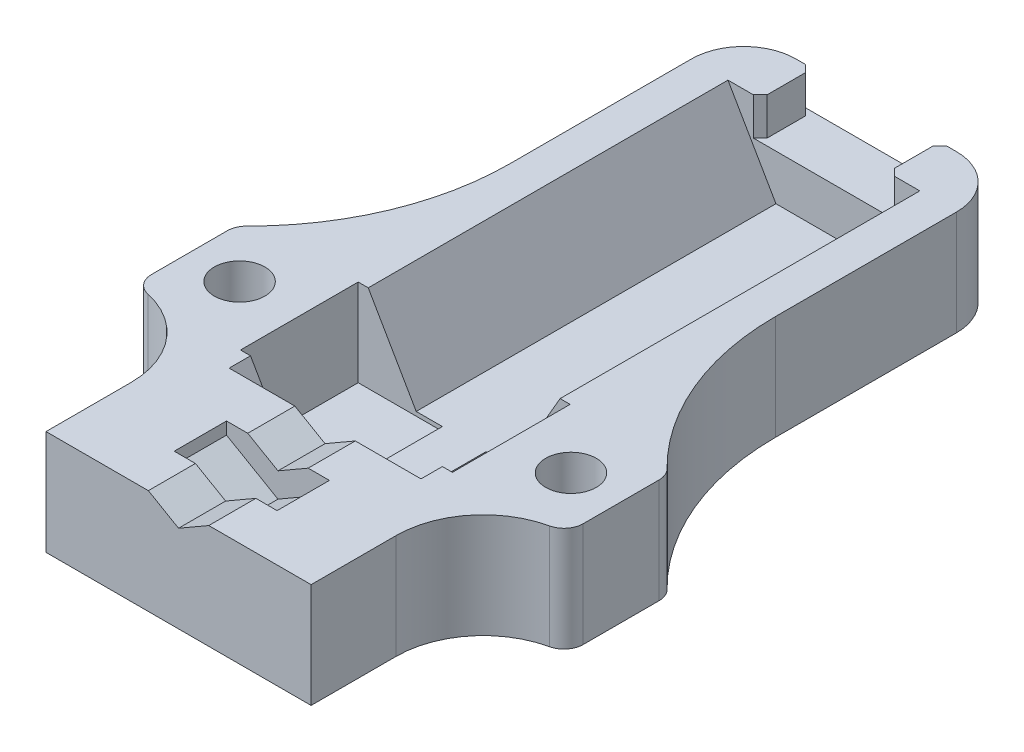
from build123d import *

# Parameters (mm, degrees)
ESBO_O2_R                = 1.6
RESSALTO_EXTRUS_O1_DEPTH = 6
ESBO_O3_W                = 4.825
ESBO_O3_H                = 6.75
CORTE_EXTRUS_O1_DEPTH    = 5
CORTE_EXTRUS_O10_DEPTH   = 28.6
ESBO_O18_W               = 7.3
ESBO_O18_H               = 2.15
CORTE_EXTRUS_O13_DEPTH   = 3
ESBO_O19_R               = 1.6
RESSALTO_EXTRUS_O2_DEPTH = 1
ESBO_O25_R               = 1.6
ESBO_O25_R_2             = 1.45
RESSALTO_EXTRUS_O3_DEPTH = 5
CHANFRO1_SIZE            = 0.4
CORTE_EXTRUS_O16_DEPTH   = 0.3
CORTE_EXTRUS_O17_DEPTH   = 0.3
CORTE_EXTRUS_O18_DEPTH   = 1.5
CORTE_EXTRUS_O19_DEPTH   = 8.4


with BuildPart() as part:
    # Esboço2 → Ressalto-extrusão1 (new body)
    with BuildSketch(Plane.XZ.offset(4.549476945)):
        with BuildLine():
            Line((8.345502404, 42.825), (8.345502404, 47.175))
            ThreePointArc((8.345502404, 47.175), (8.103648042, 47.863175897), (7.484436831, 48.248736625))
            ThreePointArc((7.484436831, 48.248736625), (4.669840418, 50.001285388), (3.570502404, 53.129357648))
            Line((3.570502404, 53.129357648), (3.570502404, 58))
            Line((3.570502404, 58), (-11.629497596, 58))
            Line((-11.629497596, 58), (-11.629497596, 53.129357648))
            ThreePointArc((-11.629497596, 53.129357648), (-12.728835609, 50.001285388), (-15.543432022, 48.248736625))
            ThreePointArc((-15.543432022, 48.248736625), (-16.162643233, 47.863175897), (-16.404497596, 47.175))
            Line((-16.404497596, 47.175), (-16.404497596, 42.825))
            ThreePointArc((-16.404497596, 42.825), (-16.319665941, 42.401404403), (-16.07825536, 42.043143925))
            ThreePointArc((-16.07825536, 42.043143925), (-12.786292881, 37.157773764), (-11.629497596, 31.381470169))
            Line((-11.629497596, 31.381470169), (-11.629497596, 21))
            ThreePointArc((-11.629497596, 21), (-10.750817939, 18.878679656), (-8.629497596, 18))
            Line((-8.629497596, 18), (0.570502404, 18))
            ThreePointArc((0.570502404, 18), (2.691822748, 18.878679656), (3.570502404, 21))
            Line((3.570502404, 21), (3.570502404, 31.381470169))
            ThreePointArc((3.570502404, 31.381470169), (4.72729769, 37.157773764), (8.019260168, 42.043143925))
            ThreePointArc((8.019260168, 42.043143925), (8.26067075, 42.401404403), (8.345502404, 42.825))
        make_face()
        with Locations((5.470502404, 45)):
            Circle(ESBO_O2_R, mode=Mode.SUBTRACT)
        with Locations((-13.529497596, 45)):
            Circle(ESBO_O2_R, mode=Mode.SUBTRACT)
    extrude(amount=RESSALTO_EXTRUS_O1_DEPTH)

    # Esboço3 → Corte-extrusão1 (cut)
    with BuildSketch(Plane.XZ.offset(4.549476945)):
        with Locations((-7.691997596, 45)):
            Rectangle(ESBO_O3_W, ESBO_O3_H)
        with Locations((-0.366997596, 45)):
            Rectangle(ESBO_O3_W, ESBO_O3_H)
    extrude(amount=CORTE_EXTRUS_O1_DEPTH, mode=Mode.SUBTRACT)

    # Esboço16 → Corte-extrusão10 (cut)
    with BuildSketch(Plane(origin=(0, 0, 21), x_dir=(-1, 0, 0), z_dir=(0, 0, -1))):
        Polygon((-1.470502404, -4.549476945), (9.529497596, -4.549476945), (6.779497596, -9.312616666), (1.279497596, -9.312616666), align=None)
    extrude(amount=-CORTE_EXTRUS_O10_DEPTH, mode=Mode.SUBTRACT)

    # Esboço18 → Corte-extrusão13 (cut)
    with BuildSketch(Plane(origin=(0, 0, 18), x_dir=(-1, 0, 0), z_dir=(0, 0, -1))):
        with Locations((4.029497596, -5.624476945)):
            Rectangle(ESBO_O18_W, ESBO_O18_H)
    extrude(amount=-CORTE_EXTRUS_O13_DEPTH, mode=Mode.SUBTRACT)

    # Esboço19 → Ressalto-extrusão2 (add)
    with BuildSketch(Plane.XZ.offset(10.549476945)):
        with Locations((5.470502404, 45)):
            Circle(ESBO_O19_R)
        with Locations((-13.529497596, 45)):
            Circle(ESBO_O19_R)
    extrude(amount=-RESSALTO_EXTRUS_O2_DEPTH)

    # Esboço25 → Ressalto-extrusão3 (add)
    with BuildSketch(Plane(origin=(0, -4.549476945, 0), x_dir=(1, 0, 0), z_dir=(0, 1, 0))):
        with Locations((-13.529497596, -45)):
            Circle(ESBO_O25_R)
        with Locations((-13.529497596, -45)):
            Circle(ESBO_O25_R_2, mode=Mode.SUBTRACT)
        with Locations((5.470502404, -45)):
            Circle(ESBO_O25_R)
        with Locations((5.470502404, -45)):
            Circle(ESBO_O25_R_2, mode=Mode.SUBTRACT)
    extrude(amount=-RESSALTO_EXTRUS_O3_DEPTH)

    # Chanfro1
    chanfro1_edges = [part.edges().sort_by_distance(p)[0] for p in [
        (-7.679497596, -5.624476945, 18),
        (-0.379497596, -5.624476945, 18),
        (-7.679497596, -5.624476945, 21),
        (-0.379497596, -5.624476945, 21),
    ]]
    chamfer(chanfro1_edges, length=CHANFRO1_SIZE)

    # Esboço27 → Corte-extrusão16 (cut)
    with BuildSketch(Plane.XZ.offset(10.549476945)):
        with BuildLine():
            ThreePointArc((-15.791149409, 45.59477117), (-14.128863589, 41.002863196), (-10.783055771, 37.445563232))
            ThreePointArc((-10.783055771, 37.445563232), (-10.055900078, 37.303954579), (-9.465074716, 37.750870461))
            ThreePointArc((-9.465074716, 37.750870461), (-8.004510861, 42.330181861), (-8.389618712, 47.121322812))
            ThreePointArc((-8.389618712, 47.121322812), (-9.230333295, 48.294029882), (-10.626882746, 48.656924514))
            ThreePointArc((-10.626882746, 48.656924514), (-12.491262269, 48.385486336), (-14.317843178, 47.923759282))
            ThreePointArc((-14.317843178, 47.923759282), (-15.484623823, 47.03136175), (-15.791149409, 45.59477117))
        make_face()
        with BuildLine():
            ThreePointArc((-8.870874134, 46.98570121), (-8.501249947, 42.387193093), (-9.903090304, 37.991997698))
            ThreePointArc((-9.903090304, 37.991997698), (-10.168736042, 37.791056258), (-10.495678356, 37.854726062))
            ThreePointArc((-10.495678356, 37.854726062), (-13.702875766, 41.264653903), (-15.296296269, 45.666327927))
            ThreePointArc((-15.296296269, 45.666327927), (-15.06207332, 46.764058415), (-14.170510543, 47.445959016))
            ThreePointArc((-14.170510543, 47.445959016), (-12.393846515, 47.895067973), (-10.580416835, 48.159088277))
            ThreePointArc((-10.580416835, 48.159088277), (-9.513282655, 47.881792499), (-8.870874134, 46.98570121))
        make_face(mode=Mode.SUBTRACT)
        with BuildLine():
            ThreePointArc((-5.90068073, 32.871710451), (-7.939750711, 30.082662839), (-9.648969405, 27.080136499))
            ThreePointArc((-9.648969405, 27.080136499), (-10.438572938, 25.143149411), (-10.935792993, 23.111360807))
            ThreePointArc((-10.935792993, 23.111360807), (-8.741507477, 19.157085505), (-4.397786444, 20.415365948))
            ThreePointArc((-4.397786444, 20.415365948), (-5.835058552, 21.518302433), (-6.815209861, 23.041957058))
            ThreePointArc((-6.815209861, 23.041957058), (-6.816302032, 23.510303091), (-6.483059558, 23.839390699))
            ThreePointArc((-6.483059558, 23.839390699), (-4.029497596, 24.313961391), (-1.575935633, 23.839390699))
            ThreePointArc((-1.575935633, 23.839390699), (-1.242693159, 23.510303091), (-1.24378533, 23.041957058))
            ThreePointArc((-1.24378533, 23.041957058), (-2.223936639, 21.518302433), (-3.661208747, 20.415365948))
            ThreePointArc((-3.661208747, 20.415365948), (0.682512286, 19.157085505), (2.876797802, 23.111360807))
            ThreePointArc((2.876797802, 23.111360807), (2.379577747, 25.143149411), (1.589974213, 27.080136499))
            ThreePointArc((1.589974213, 27.080136499), (-0.11924448, 30.082662839), (-2.158314461, 32.871710451))
            ThreePointArc((-2.158314461, 32.871710451), (-4.029497596, 33.755611739), (-5.90068073, 32.871710451))
        make_face()
        with BuildLine():
            ThreePointArc((-5.514481186, 32.554141699), (-4.029497596, 33.255611739), (-2.544514005, 32.554141699))
            ThreePointArc((-2.544514005, 32.554141699), (-0.539003123, 29.810996349), (1.142085178, 26.857885713))
            ThreePointArc((1.142085178, 26.857885713), (1.903954139, 24.98893468), (2.383709498, 23.028512003))
            ThreePointArc((2.383709498, 23.028512003), (0.740199646, 19.73467866), (-2.899233616, 20.286936077))
            ThreePointArc((-2.899233616, 20.286936077), (-1.65337111, 21.412039739), (-0.783125171, 22.847554852))
            ThreePointArc((-0.783125171, 22.847554852), (-0.781131334, 23.7025547), (-1.389489779, 24.303328134))
            ThreePointArc((-1.389489779, 24.303328134), (-4.029497596, 24.813961391), (-6.669505412, 24.303328134))
            ThreePointArc((-6.669505412, 24.303328134), (-7.277863858, 23.7025547), (-7.27587002, 22.847554852))
            ThreePointArc((-7.27587002, 22.847554852), (-6.405624081, 21.412039739), (-5.159761575, 20.286936077))
            ThreePointArc((-5.159761575, 20.286936077), (-8.799194837, 19.73467866), (-10.442704689, 23.028512003))
            ThreePointArc((-10.442704689, 23.028512003), (-9.96294933, 24.98893468), (-9.201080369, 26.857885713))
            ThreePointArc((-9.201080369, 26.857885713), (-7.519992068, 29.810996349), (-5.514481186, 32.554141699))
        make_face(mode=Mode.SUBTRACT)
        with BuildLine():
            ThreePointArc((-9.14787736, 34.539793749), (-7.75752945, 35.062597519), (-6.367181541, 34.539793749))
            ThreePointArc((-6.367181541, 34.539793749), (-6.068058946, 34.559583314), (-6.087848512, 34.858705909))
            ThreePointArc((-6.087848512, 34.858705909), (-7.75752945, 35.486545519), (-9.427210389, 34.858705909))
            ThreePointArc((-9.427210389, 34.858705909), (-9.446999955, 34.559583314), (-9.14787736, 34.539793749))
        make_face()
        with BuildLine():
            ThreePointArc((1.368215198, 34.858705909), (1.388004763, 34.559583314), (1.088882169, 34.539793749))
            ThreePointArc((1.088882169, 34.539793749), (-0.301465741, 35.062597519), (-1.691813651, 34.539793749))
            ThreePointArc((-1.691813651, 34.539793749), (-1.990936245, 34.559583314), (-1.971146679, 34.858705909))
            ThreePointArc((-1.971146679, 34.858705909), (-0.301465741, 35.486545519), (1.368215198, 34.858705909))
        make_face()
        with BuildLine():
            ThreePointArc((7.732154218, 45.59477117), (7.425628632, 47.03136175), (6.258847987, 47.923759282))
            ThreePointArc((6.258847987, 47.923759282), (4.432267078, 48.385486336), (2.567887555, 48.656924514))
            ThreePointArc((2.567887555, 48.656924514), (1.171338104, 48.294029882), (0.330623521, 47.121322812))
            ThreePointArc((0.330623521, 47.121322812), (-0.05448433, 42.330181861), (1.406079525, 37.750870461))
            ThreePointArc((1.406079525, 37.750870461), (1.996904887, 37.303954579), (2.72406058, 37.445563232))
            ThreePointArc((2.72406058, 37.445563232), (6.069868398, 41.002863196), (7.732154218, 45.59477117))
        make_face()
        with BuildLine():
            ThreePointArc((7.237301078, 45.666327927), (7.003078129, 46.764058415), (6.111515352, 47.445959016))
            ThreePointArc((6.111515352, 47.445959016), (4.334851324, 47.895067973), (2.521421644, 48.159088277))
            ThreePointArc((2.521421644, 48.159088277), (1.454287464, 47.881792499), (0.811878943, 46.98570121))
            ThreePointArc((0.811878943, 46.98570121), (0.442254755, 42.387193093), (1.844095113, 37.991997698))
            ThreePointArc((1.844095113, 37.991997698), (2.109740851, 37.791056258), (2.436683165, 37.854726062))
            ThreePointArc((2.436683165, 37.854726062), (5.643880575, 41.264653903), (7.237301078, 45.666327927))
        make_face(mode=Mode.SUBTRACT)
    extrude(amount=-CORTE_EXTRUS_O16_DEPTH, mode=Mode.SUBTRACT)

    # Esboço28 → Corte-extrusão17 (cut)
    with BuildSketch(Plane.XZ.offset(10.549476945)):
        with BuildLine():
            add(Edge.make_bspline(
                [(-6.087189903, 51.314423077), (-6.087424867, 51.29078602), (-6.087878866, 51.245114298), (-6.087974383, 51.178990069), (-6.090282133, 51.117911614), (-6.091590244, 51.061583522), (-6.094774461, 51.010306571), (-6.098250442, 50.964013304), (-6.102492612, 50.922735115), (-6.10859176, 50.875299307), (-6.118400885, 50.822070525), (-6.134005241, 50.764194274), (-6.152569087, 50.712336539), (-6.169714824, 50.681818787), (-6.177935096, 50.6671875)],
                knots=[0, 0, 0, 0, 7.0916e-05, 0.000137025, 0.000198349, 0.000254268, 0.000306038, 0.000352452, 0.000393533, 0.000430506, 0.000495922, 0.000555693, 0.000610275, 0.000660544, 0.000660544, 0.000660544, 0.000660544], degree=3))
            add(Edge.make_bspline(
                [(-6.177935096, 50.6671875), (-6.19431015, 50.641825635), (-6.227003849, 50.591189274), (-6.283923273, 50.521285704), (-6.345286345, 50.455867436), (-6.412319513, 50.396227642), (-6.484675706, 50.341929128), (-6.562671332, 50.293274727), (-6.645696045, 50.249218074), (-6.734779714, 50.210683173), (-6.830143669, 50.176920662), (-6.93265506, 50.148439052), (-7.042482273, 50.123445739), (-7.160204116, 50.104437592), (-7.285159671, 50.087590703), (-7.417785613, 50.077468123), (-7.557870204, 50.070614796), (-7.653887443, 50.069700236), (-7.70317548, 50.069230769)],
                knots=[0, 0, 0, 0, 9.0506e-05, 0.0001807, 0.000269975, 0.000359359, 0.000449503, 0.000541043, 0.000634864, 0.000731215, 0.000831954, 0.000938112, 0.001050228, 0.001169674, 0.001295723, 0.001428376, 0.001568556, 0.001716413, 0.001716413, 0.001716413, 0.001716413], degree=3))
            add(Edge.make_bspline(
                [(-7.70317548, 50.069230769), (-7.759474078, 50.069882495), (-7.868721015, 50.071147162), (-8.027520591, 50.078737296), (-8.175975532, 50.092154071), (-8.314031683, 50.112391128), (-8.441912356, 50.136088273), (-8.559246643, 50.167097088), (-8.666302858, 50.202656415), (-8.763365259, 50.244195792), (-8.850484432, 50.291645515), (-8.928340646, 50.345570078), (-8.997127821, 50.405818143), (-9.057236736, 50.472121045), (-9.10750477, 50.545286103), (-9.149231915, 50.62419065), (-9.181342943, 50.709740593), (-9.19541588, 50.769567284), (-9.202574519, 50.8)],
                knots=[0, 0, 0, 0, 0.000168897, 0.000327743, 0.000476823, 0.000615864, 0.000746219, 0.000866767, 0.000979652, 0.001084366, 0.001183072, 0.001276762, 0.001367894, 0.001456831, 0.001544515, 0.001633494, 0.001724018, 0.001817741, 0.001817741, 0.001817741, 0.001817741], degree=3))
            Line((-9.202574519, 50.8), (-7.808944711, 50.8))
            add(Edge.make_bspline(
                [(-7.808944711, 50.8), (-7.804445623, 50.793313672), (-7.795395723, 50.779864148), (-7.775261879, 50.763974531), (-7.751564279, 50.750131837), (-7.722111816, 50.740056208), (-7.68765338, 50.73237713), (-7.647195578, 50.727389868), (-7.600882372, 50.723601265), (-7.567968832, 50.723258513), (-7.550531249, 50.723076923)],
                knots=[0, 0, 0, 0, 2.4038e-05, 4.8353e-05, 7.6082e-05, 0.000106118, 0.000141253, 0.000181879, 0.000228293, 0.000280591, 0.000280591, 0.000280591, 0.000280591], degree=3))
            add(Edge.make_bspline(
                [(-7.550531249, 50.723076923), (-7.53229535, 50.723257863), (-7.49697238, 50.723608344), (-7.446145834, 50.727679726), (-7.399234782, 50.735133011), (-7.356366875, 50.744377614), (-7.317268768, 50.756437769), (-7.282254746, 50.771275824), (-7.251453798, 50.789404305), (-7.224239395, 50.810242808), (-7.200753238, 50.834326385), (-7.180562713, 50.862164026), (-7.163231869, 50.893155654), (-7.149285173, 50.928136955), (-7.138788876, 50.966472666), (-7.130752196, 51.008240443), (-7.12694668, 51.053536734), (-7.126093606, 51.084850963), (-7.125651442, 51.101081731)],
                knots=[0, 0, 0, 0, 5.4701e-05, 0.000105955, 0.000152788, 0.000197113, 0.000237409, 0.000275364, 0.000310923, 0.00034434, 0.000377913, 0.000411449, 0.00044723, 0.000484168, 0.000524122, 0.000566318, 0.000611586, 0.000660297, 0.000660297, 0.000660297, 0.000660297], degree=3))
            add(Edge.make_bspline(
                [(-7.125651442, 51.101081731), (-7.125472068, 51.114106739), (-7.12516839, 51.136157963), (-7.126812937, 51.165386498), (-7.127821408, 51.188252687), (-7.129198621, 51.202047476), (-7.129858172, 51.208653846)],
                knots=[0, 0, 0, 0, 3.9062e-05, 6.6132e-05, 8.78e-05, 0.000107714, 0.000107714, 0.000107714, 0.000107714], degree=3))
            add(Edge.make_bspline(
                [(-7.129858172, 51.208653846), (-7.159484813, 51.187745332), (-7.218871426, 51.145834206), (-7.316475545, 51.094719411), (-7.419141897, 51.049607281), (-7.52920486, 51.014388973), (-7.646079907, 50.987595743), (-7.770299564, 50.96753626), (-7.902493641, 50.956478393), (-7.993220221, 50.954738023), (-8.039713942, 50.953846154)],
                knots=[0, 0, 0, 0, 0.000108674, 0.000217838, 0.000329812, 0.000444791, 0.000563887, 0.000689264, 0.000821967, 0.000961454, 0.000961454, 0.000961454, 0.000961454], degree=3))
            add(Edge.make_bspline(
                [(-8.039713942, 50.953846154), (-8.085831038, 50.954695893), (-8.175697459, 50.956351744), (-8.30685189, 50.971367096), (-8.43100093, 50.994281196), (-8.548128751, 51.027381068), (-8.65812182, 51.070042739), (-8.760691763, 51.122616736), (-8.856339739, 51.184132297), (-8.944110243, 51.254942023), (-9.022550355, 51.334240153), (-9.091638503, 51.419781093), (-9.149922925, 51.512131493), (-9.197483035, 51.610937026), (-9.234093098, 51.716271482), (-9.26067414, 51.827554655), (-9.276404575, 51.945383457), (-9.278450558, 52.026113878), (-9.279497596, 52.067427885)],
                knots=[0, 0, 0, 0, 0.000138305, 0.000269509, 0.000395506, 0.000516687, 0.00063409, 0.000748855, 0.000861874, 0.000974688, 0.001086449, 0.001195884, 0.001303923, 0.00141332, 0.001524127, 0.001637821, 0.001756046, 0.001879962, 0.001879962, 0.001879962, 0.001879962], degree=3))
            add(Edge.make_bspline(
                [(-9.279497596, 52.067427885), (-9.278459807, 52.108544512), (-9.276432089, 52.18888162), (-9.260550093, 52.306268974), (-9.234288292, 52.417523337), (-9.196691359, 52.522569787), (-9.149342353, 52.621855757), (-9.090299081, 52.714216607), (-9.021636492, 52.800858135), (-8.941848125, 52.879812794), (-8.854204229, 52.952038633), (-8.757767874, 53.013823875), (-8.655015631, 53.067345531), (-8.544801228, 53.110524885), (-8.42731432, 53.143364464), (-8.303133458, 53.167370563), (-8.171675066, 53.182015999), (-8.081619281, 53.183735125), (-8.035507211, 53.184615385)],
                knots=[0, 0, 0, 0, 0.000123316, 0.000240945, 0.000354639, 0.000465646, 0.000575043, 0.000683912, 0.000793815, 0.000906, 0.001020039, 0.001133889, 0.001248929, 0.001367111, 0.001488292, 0.001614402, 0.001746204, 0.001884508, 0.001884508, 0.001884508, 0.001884508], degree=3))
            add(Edge.make_bspline(
                [(-8.035507211, 53.184615385), (-7.987200923, 53.183635698), (-7.893206501, 53.181729423), (-7.755956823, 53.168569004), (-7.626711865, 53.14595936), (-7.504930591, 53.113881932), (-7.390043307, 53.073222839), (-7.282265112, 53.022246224), (-7.180006588, 52.963216924), (-7.118139633, 52.915311467), (-7.087189903, 52.891346154)],
                knots=[0, 0, 0, 0, 0.000144912, 0.000281969, 0.000413178, 0.0005381, 0.000659375, 0.000778203, 0.000895391, 0.001012702, 0.001012702, 0.001012702, 0.001012702], degree=3))
            Line((-7.087189903, 52.891346154), (-7.078776442, 53.107692308))
            Line((-7.078776442, 53.107692308), (-6.087189903, 53.107692308))
            Line((-6.087189903, 53.107692308), (-6.087189903, 51.314423077))
        make_face()
        with BuildLine():
            add(Edge.make_bspline(
                [(-8.16411298, 52.048197115), (-8.163617163, 52.031949078), (-8.162639754, 51.999919192), (-8.155966719, 51.953204186), (-8.145233991, 51.909065279), (-8.130039502, 51.867466833), (-8.110084538, 51.828451892), (-8.086082563, 51.791636695), (-8.057431268, 51.757536249), (-8.024339633, 51.726586416), (-7.98793433, 51.698245783), (-7.947835055, 51.67420567), (-7.904975891, 51.653689837), (-7.859081896, 51.636862695), (-7.810204188, 51.623711807), (-7.758392472, 51.614000274), (-7.703487581, 51.608707939), (-7.665926631, 51.608036347), (-7.646685096, 51.607692308)],
                knots=[0, 0, 0, 0, 4.8737e-05, 9.6076e-05, 0.00014126, 0.0001848, 0.000228608, 0.000272446, 0.000316382, 0.000361868, 0.000408146, 0.000454526, 0.000501834, 0.000550508, 0.000600949, 0.000653519, 0.000708473, 0.000766194, 0.000766194, 0.000766194, 0.000766194], degree=3))
            add(Edge.make_bspline(
                [(-7.646685096, 51.607692308), (-7.627443466, 51.60803615), (-7.58988233, 51.608707357), (-7.534978757, 51.614002435), (-7.483162356, 51.623704215), (-7.434301125, 51.636889407), (-7.388518635, 51.653533262), (-7.346019296, 51.674378224), (-7.30602662, 51.698224572), (-7.269634202, 51.726591992), (-7.236539198, 51.757534822), (-7.207888771, 51.79163707), (-7.183886567, 51.828451791), (-7.163931663, 51.867466859), (-7.148737158, 51.909065272), (-7.138004435, 51.953204188), (-7.131331398, 51.999919191), (-7.13035399, 52.031949078), (-7.129858172, 52.048197115)],
                knots=[0, 0, 0, 0, 5.772e-05, 0.000112675, 0.000165244, 0.000215686, 0.00026436, 0.000311127, 0.000357506, 0.000403784, 0.000449271, 0.000493207, 0.000537044, 0.000580853, 0.000624392, 0.000669576, 0.000716915, 0.000765653, 0.000765653, 0.000765653, 0.000765653], degree=3))
            add(Edge.make_bspline(
                [(-7.129858172, 52.048197115), (-7.130337538, 52.064648396), (-7.131276852, 52.096884534), (-7.138124403, 52.143957422), (-7.148570984, 52.188652571), (-7.164554631, 52.23045022), (-7.184453694, 52.2697553), (-7.208640724, 52.306807044), (-7.237568853, 52.341032766), (-7.270798978, 52.372263532), (-7.307427391, 52.400442289), (-7.347127943, 52.425349593), (-7.390352623, 52.445536338), (-7.435784377, 52.463145969), (-7.484487607, 52.476574683), (-7.536100661, 52.484928175), (-7.59042702, 52.491574984), (-7.627632152, 52.492059546), (-7.646685096, 52.492307692)],
                knots=[0, 0, 0, 0, 4.9337e-05, 9.6676e-05, 0.000142444, 0.000186757, 0.000230565, 0.000274402, 0.000319185, 0.000364672, 0.00041095, 0.000457643, 0.000504952, 0.000553837, 0.000603699, 0.000656162, 0.000710581, 0.000767701, 0.000767701, 0.000767701, 0.000767701], degree=3))
            add(Edge.make_bspline(
                [(-7.646685096, 52.492307692), (-7.665737345, 52.492055643), (-7.702941121, 52.491563462), (-7.757081052, 52.484994879), (-7.808466693, 52.476491671), (-7.856987877, 52.463155941), (-7.902410109, 52.445526136), (-7.945663437, 52.425379583), (-7.985395663, 52.400248769), (-8.02251901, 52.372464549), (-8.055825106, 52.341035741), (-8.08464727, 52.306623254), (-8.109614103, 52.269951058), (-8.129376876, 52.230424086), (-8.145411217, 52.188659854), (-8.155843653, 52.143955381), (-8.162695125, 52.096885077), (-8.163633893, 52.06464858), (-8.16411298, 52.048197115)],
                knots=[0, 0, 0, 0, 5.712e-05, 0.000111539, 0.00016341, 0.000213272, 0.000262157, 0.000309465, 0.000356159, 0.000402914, 0.000448401, 0.000493184, 0.000537354, 0.000581162, 0.000625475, 0.000671242, 0.000718581, 0.000767919, 0.000767919, 0.000767919, 0.000767919], degree=3))
        make_face(mode=Mode.SUBTRACT)
        with BuildLine():
            add(Edge.make_bspline(
                [(-2.471805288, 51.314423077), (-2.472040251, 51.29078602), (-2.47249425, 51.245114298), (-2.472589768, 51.178990069), (-2.474897518, 51.117911614), (-2.476205628, 51.061583522), (-2.479389845, 51.010306571), (-2.482865826, 50.964013304), (-2.487107996, 50.922735115), (-2.493207145, 50.875299307), (-2.50301627, 50.822070525), (-2.518620625, 50.764194274), (-2.537184472, 50.712336539), (-2.554330209, 50.681818787), (-2.56255048, 50.6671875)],
                knots=[0, 0, 0, 0, 7.0916e-05, 0.000137025, 0.000198349, 0.000254268, 0.000306038, 0.000352452, 0.000393533, 0.000430506, 0.000495922, 0.000555693, 0.000610275, 0.000660544, 0.000660544, 0.000660544, 0.000660544], degree=3))
            add(Edge.make_bspline(
                [(-2.56255048, 50.6671875), (-2.578925535, 50.641825635), (-2.611619233, 50.591189274), (-2.668538657, 50.521285704), (-2.72990173, 50.455867436), (-2.796934897, 50.396227642), (-2.869291091, 50.341929128), (-2.947286716, 50.293274727), (-3.030311429, 50.249218074), (-3.119395099, 50.210683173), (-3.214759054, 50.176920662), (-3.317270444, 50.148439052), (-3.427097657, 50.123445739), (-3.544819501, 50.104437592), (-3.669775055, 50.087590703), (-3.802400998, 50.077468123), (-3.942485588, 50.070614796), (-4.038502828, 50.069700236), (-4.087790865, 50.069230769)],
                knots=[0, 0, 0, 0, 9.0506e-05, 0.0001807, 0.000269975, 0.000359359, 0.000449503, 0.000541043, 0.000634864, 0.000731215, 0.000831954, 0.000938112, 0.001050228, 0.001169674, 0.001295723, 0.001428376, 0.001568556, 0.001716413, 0.001716413, 0.001716413, 0.001716413], degree=3))
            add(Edge.make_bspline(
                [(-4.087790865, 50.069230769), (-4.144089462, 50.069882495), (-4.253336399, 50.071147162), (-4.412135976, 50.078737296), (-4.560590916, 50.092154071), (-4.698647067, 50.112391128), (-4.826527741, 50.136088273), (-4.943862028, 50.167097088), (-5.050918243, 50.202656415), (-5.147980644, 50.244195792), (-5.235099816, 50.291645515), (-5.312956031, 50.345570078), (-5.381743206, 50.405818143), (-5.441852121, 50.472121045), (-5.492120155, 50.545286103), (-5.5338473, 50.62419065), (-5.565958327, 50.709740593), (-5.580031264, 50.769567284), (-5.587189903, 50.8)],
                knots=[0, 0, 0, 0, 0.000168897, 0.000327743, 0.000476823, 0.000615864, 0.000746219, 0.000866767, 0.000979652, 0.001084366, 0.001183072, 0.001276762, 0.001367894, 0.001456831, 0.001544515, 0.001633494, 0.001724018, 0.001817741, 0.001817741, 0.001817741, 0.001817741], degree=3))
            Line((-5.587189903, 50.8), (-4.193560096, 50.8))
            add(Edge.make_bspline(
                [(-4.193560096, 50.8), (-4.189061007, 50.793313672), (-4.180011108, 50.779864148), (-4.159877263, 50.763974531), (-4.136179664, 50.750131837), (-4.106727201, 50.740056208), (-4.072268765, 50.73237713), (-4.031810963, 50.727389868), (-3.985497757, 50.723601265), (-3.952584217, 50.723258513), (-3.935146634, 50.723076923)],
                knots=[0, 0, 0, 0, 2.4038e-05, 4.8353e-05, 7.6082e-05, 0.000106118, 0.000141253, 0.000181879, 0.000228293, 0.000280591, 0.000280591, 0.000280591, 0.000280591], degree=3))
            add(Edge.make_bspline(
                [(-3.935146634, 50.723076923), (-3.916910734, 50.723257863), (-3.881587765, 50.723608344), (-3.830761218, 50.727679726), (-3.783850166, 50.735133011), (-3.740982259, 50.744377614), (-3.701884153, 50.756437769), (-3.66687013, 50.771275824), (-3.636069182, 50.789404305), (-3.608854779, 50.810242808), (-3.585368623, 50.834326385), (-3.565178097, 50.862164026), (-3.547847253, 50.893155654), (-3.533900557, 50.928136955), (-3.523404261, 50.966472666), (-3.51536758, 51.008240443), (-3.511562064, 51.053536734), (-3.510708991, 51.084850963), (-3.510266826, 51.101081731)],
                knots=[0, 0, 0, 0, 5.4701e-05, 0.000105955, 0.000152788, 0.000197113, 0.000237409, 0.000275364, 0.000310923, 0.00034434, 0.000377913, 0.000411449, 0.00044723, 0.000484168, 0.000524122, 0.000566318, 0.000611586, 0.000660297, 0.000660297, 0.000660297, 0.000660297], degree=3))
            add(Edge.make_bspline(
                [(-3.510266826, 51.101081731), (-3.510087453, 51.114106739), (-3.509783775, 51.136157963), (-3.511428321, 51.165386498), (-3.512436792, 51.188252687), (-3.513814005, 51.202047476), (-3.514473557, 51.208653846)],
                knots=[0, 0, 0, 0, 3.9062e-05, 6.6132e-05, 8.78e-05, 0.000107714, 0.000107714, 0.000107714, 0.000107714], degree=3))
            add(Edge.make_bspline(
                [(-3.514473557, 51.208653846), (-3.544100197, 51.187745332), (-3.60348681, 51.145834206), (-3.70109093, 51.094719411), (-3.803757282, 51.049607281), (-3.913820244, 51.014388973), (-4.030695292, 50.987595743), (-4.154914948, 50.96753626), (-4.287109025, 50.956478393), (-4.377835606, 50.954738023), (-4.424329326, 50.953846154)],
                knots=[0, 0, 0, 0, 0.000108674, 0.000217838, 0.000329812, 0.000444791, 0.000563887, 0.000689264, 0.000821967, 0.000961454, 0.000961454, 0.000961454, 0.000961454], degree=3))
            add(Edge.make_bspline(
                [(-4.424329326, 50.953846154), (-4.470446422, 50.954695893), (-4.560312844, 50.956351744), (-4.691467275, 50.971367096), (-4.815616314, 50.994281196), (-4.932744136, 51.027381068), (-5.042737205, 51.070042739), (-5.145307148, 51.122616736), (-5.240955124, 51.184132297), (-5.328725627, 51.254942023), (-5.40716574, 51.334240153), (-5.476253888, 51.419781093), (-5.534538309, 51.512131493), (-5.58209842, 51.610937026), (-5.618708482, 51.716271482), (-5.645289525, 51.827554655), (-5.66101996, 51.945383457), (-5.663065943, 52.026113878), (-5.66411298, 52.067427885)],
                knots=[0, 0, 0, 0, 0.000138305, 0.000269509, 0.000395506, 0.000516687, 0.00063409, 0.000748855, 0.000861874, 0.000974688, 0.001086449, 0.001195884, 0.001303923, 0.00141332, 0.001524127, 0.001637821, 0.001756046, 0.001879962, 0.001879962, 0.001879962, 0.001879962], degree=3))
            add(Edge.make_bspline(
                [(-5.66411298, 52.067427885), (-5.663075192, 52.108544512), (-5.661047474, 52.18888162), (-5.645165478, 52.306268974), (-5.618903676, 52.417523337), (-5.581306744, 52.522569787), (-5.533957738, 52.621855757), (-5.474914466, 52.714216607), (-5.406251876, 52.800858135), (-5.326463509, 52.879812794), (-5.238819614, 52.952038633), (-5.142383258, 53.013823875), (-5.039631016, 53.067345531), (-4.929416612, 53.110524885), (-4.811929705, 53.143364464), (-4.687748843, 53.167370563), (-4.556290451, 53.182015999), (-4.466234666, 53.183735125), (-4.420122596, 53.184615385)],
                knots=[0, 0, 0, 0, 0.000123316, 0.000240945, 0.000354639, 0.000465646, 0.000575043, 0.000683912, 0.000793815, 0.000906, 0.001020039, 0.001133889, 0.001248929, 0.001367111, 0.001488292, 0.001614402, 0.001746204, 0.001884508, 0.001884508, 0.001884508, 0.001884508], degree=3))
            add(Edge.make_bspline(
                [(-4.420122596, 53.184615385), (-4.371816308, 53.183635698), (-4.277821885, 53.181729423), (-4.140572207, 53.168569004), (-4.011327249, 53.14595936), (-3.889545975, 53.113881932), (-3.774658691, 53.073222839), (-3.666880497, 53.022246224), (-3.564621972, 52.963216924), (-3.502755018, 52.915311467), (-3.471805288, 52.891346154)],
                knots=[0, 0, 0, 0, 0.000144912, 0.000281969, 0.000413178, 0.0005381, 0.000659375, 0.000778203, 0.000895391, 0.001012702, 0.001012702, 0.001012702, 0.001012702], degree=3))
            Line((-3.471805288, 52.891346154), (-3.463391826, 53.107692308))
            Line((-3.463391826, 53.107692308), (-2.471805288, 53.107692308))
            Line((-2.471805288, 53.107692308), (-2.471805288, 51.314423077))
        make_face()
        with BuildLine():
            add(Edge.make_bspline(
                [(-4.548728365, 52.048197115), (-4.548232547, 52.031949078), (-4.547255139, 51.999919192), (-4.540582104, 51.953204186), (-4.529849375, 51.909065279), (-4.514654887, 51.867466833), (-4.494699922, 51.828451892), (-4.470697947, 51.791636695), (-4.442046652, 51.757536249), (-4.408955017, 51.726586416), (-4.372549715, 51.698245783), (-4.332450439, 51.67420567), (-4.289591276, 51.653689837), (-4.243697281, 51.636862695), (-4.194819573, 51.623711807), (-4.143007856, 51.614000274), (-4.088102966, 51.608707939), (-4.050542015, 51.608036347), (-4.03130048, 51.607692308)],
                knots=[0, 0, 0, 0, 4.8737e-05, 9.6076e-05, 0.00014126, 0.0001848, 0.000228608, 0.000272446, 0.000316382, 0.000361868, 0.000408146, 0.000454526, 0.000501834, 0.000550508, 0.000600949, 0.000653519, 0.000708473, 0.000766194, 0.000766194, 0.000766194, 0.000766194], degree=3))
            add(Edge.make_bspline(
                [(-4.03130048, 51.607692308), (-4.01205885, 51.60803615), (-3.974497715, 51.608707357), (-3.919594142, 51.614002435), (-3.867777741, 51.623704215), (-3.818916509, 51.636889407), (-3.77313402, 51.653533262), (-3.730634681, 51.674378224), (-3.690642005, 51.698224572), (-3.654249587, 51.726591992), (-3.621154583, 51.757534822), (-3.592504155, 51.79163707), (-3.568501951, 51.828451791), (-3.548547048, 51.867466859), (-3.533352543, 51.909065272), (-3.522619819, 51.953204188), (-3.515946783, 51.999919191), (-3.514969374, 52.031949078), (-3.514473557, 52.048197115)],
                knots=[0, 0, 0, 0, 5.772e-05, 0.000112675, 0.000165244, 0.000215686, 0.00026436, 0.000311127, 0.000357506, 0.000403784, 0.000449271, 0.000493207, 0.000537044, 0.000580853, 0.000624392, 0.000669576, 0.000716915, 0.000765653, 0.000765653, 0.000765653, 0.000765653], degree=3))
            add(Edge.make_bspline(
                [(-3.514473557, 52.048197115), (-3.514952923, 52.064648396), (-3.515892236, 52.096884534), (-3.522739787, 52.143957422), (-3.533186368, 52.188652571), (-3.549170015, 52.23045022), (-3.569069079, 52.2697553), (-3.593256108, 52.306807044), (-3.622184238, 52.341032766), (-3.655414363, 52.372263532), (-3.692042776, 52.400442289), (-3.731743327, 52.425349593), (-3.774968008, 52.445536338), (-3.820399762, 52.463145969), (-3.869102992, 52.476574683), (-3.920716046, 52.484928175), (-3.975042404, 52.491574984), (-4.012247536, 52.492059546), (-4.03130048, 52.492307692)],
                knots=[0, 0, 0, 0, 4.9337e-05, 9.6676e-05, 0.000142444, 0.000186757, 0.000230565, 0.000274402, 0.000319185, 0.000364672, 0.00041095, 0.000457643, 0.000504952, 0.000553837, 0.000603699, 0.000656162, 0.000710581, 0.000767701, 0.000767701, 0.000767701, 0.000767701], degree=3))
            add(Edge.make_bspline(
                [(-4.03130048, 52.492307692), (-4.05035273, 52.492055643), (-4.087556506, 52.491563462), (-4.141696437, 52.484994879), (-4.193082077, 52.476491671), (-4.241603261, 52.463155941), (-4.287025493, 52.445526136), (-4.330278822, 52.425379583), (-4.370011047, 52.400248769), (-4.407134394, 52.372464549), (-4.440440491, 52.341035741), (-4.469262655, 52.306623254), (-4.494229487, 52.269951058), (-4.513992261, 52.230424086), (-4.530026602, 52.188659854), (-4.540459038, 52.143955381), (-4.547310509, 52.096885077), (-4.548249277, 52.06464858), (-4.548728365, 52.048197115)],
                knots=[0, 0, 0, 0, 5.712e-05, 0.000111539, 0.00016341, 0.000213272, 0.000262157, 0.000309465, 0.000356159, 0.000402914, 0.000448401, 0.000493184, 0.000537354, 0.000581162, 0.000625475, 0.000671242, 0.000718581, 0.000767919, 0.000767919, 0.000767919, 0.000767919], degree=3))
        make_face(mode=Mode.SUBTRACT)
        with BuildLine():
            add(Edge.make_bspline(
                [(-2.048728365, 51.952644231), (-2.047597393, 52.000204858), (-2.045386405, 52.093183279), (-2.024087784, 52.228253512), (-1.991696847, 52.355576232), (-1.944298244, 52.474143238), (-1.884022684, 52.584696922), (-1.809077311, 52.685999262), (-1.722104907, 52.780140361), (-1.621100255, 52.864573797), (-1.508455137, 52.940552906), (-1.383980513, 53.006015698), (-1.248568073, 53.061095709), (-1.102752309, 53.107007454), (-0.945582546, 53.141363686), (-0.777726475, 53.166193584), (-0.598724581, 53.182406352), (-0.475648181, 53.183864821), (-0.412310096, 53.184615385)],
                knots=[0, 0, 0, 0, 0.000142581, 0.000278738, 0.000409197, 0.00053597, 0.000660768, 0.000785896, 0.00091304, 0.001044388, 0.001179898, 0.001319958, 0.001465485, 0.001617921, 0.001778012, 0.001947569, 0.002126738, 0.002316702, 0.002316702, 0.002316702, 0.002316702], degree=3))
            add(Edge.make_bspline(
                [(-0.412310096, 53.184615385), (-0.348977404, 53.183789411), (-0.225728973, 53.182182027), (-0.046471991, 53.166967529), (0.121853951, 53.142110145), (0.278941841, 53.106719809), (0.425111615, 53.062007678), (0.55998616, 53.006593592), (0.683643186, 52.941056167), (0.796121271, 52.865874549), (0.896032052, 52.781267127), (0.983085731, 52.687728529), (1.056817351, 52.585914488), (1.116778793, 52.475078752), (1.163917028, 52.356328351), (1.196672852, 52.228919593), (1.216976619, 52.093522854), (1.219307353, 52.000394506), (1.220502404, 51.952644231)],
                knots=[0, 0, 0, 0, 0.000189965, 0.00036968, 0.000539238, 0.000700046, 0.000852303, 0.000997275, 0.001136804, 0.00127148, 0.001402369, 0.001528664, 0.001653925, 0.001778435, 0.001905766, 0.002036225, 0.002172293, 0.002315475, 0.002315475, 0.002315475, 0.002315475], degree=3))
            add(Edge.make_bspline(
                [(1.220502404, 51.952644231), (1.219314127, 51.905092028), (1.216996804, 51.812357997), (1.196574334, 51.677392784), (1.16406235, 51.550302614), (1.116591552, 51.431896532), (1.057022311, 51.321234047), (0.982869524, 51.219919093), (0.896061562, 51.126404361), (0.796112997, 51.041823597), (0.683645517, 50.966634496), (0.5599855, 50.901099182), (0.425111805, 50.845684496), (0.278941786, 50.800972538), (0.121853967, 50.765582151), (-0.046471996, 50.740724781), (-0.225728972, 50.72551028), (-0.348977404, 50.723902896), (-0.412310096, 50.723076923)],
                knots=[0, 0, 0, 0, 0.000142581, 0.000278055, 0.000408514, 0.000535287, 0.000659796, 0.00078457, 0.000910865, 0.001041755, 0.001176431, 0.00131596, 0.001460931, 0.001613188, 0.001773997, 0.001943554, 0.00212327, 0.002313234, 0.002313234, 0.002313234, 0.002313234], degree=3))
            add(Edge.make_bspline(
                [(-0.412310096, 50.723076923), (-0.475643668, 50.723893891), (-0.598694158, 50.725481173), (-0.777740848, 50.740781254), (-0.945690331, 50.765500666), (-1.102545202, 50.80105182), (-1.248684829, 50.845793797), (-1.383994603, 50.901089478), (-1.508248154, 50.96663375), (-1.621316002, 51.041814389), (-1.721857276, 51.126394776), (-1.809282548, 51.219895023), (-1.883991782, 51.321222519), (-1.944305154, 51.431738237), (-1.991700686, 51.550314556), (-2.024015226, 51.677446542), (-2.045430611, 51.812297888), (-2.047610777, 51.905081748), (-2.048728365, 51.952644231)],
                knots=[0, 0, 0, 0, 0.000189965, 0.000369081, 0.000538639, 0.000698861, 0.000851118, 0.000996645, 0.001136705, 0.00127188, 0.001403229, 0.001529933, 0.001655062, 0.001779859, 0.001906632, 0.002037091, 0.002172654, 0.002315235, 0.002315235, 0.002315235, 0.002315235], degree=3))
        make_face()
        with BuildLine():
            add(Edge.make_bspline(
                [(-0.933343749, 51.953846154), (-0.93286321, 51.933793615), (-0.931923475, 51.894579211), (-0.925160626, 51.837515352), (-0.914673152, 51.783462759), (-0.898566671, 51.733037005), (-0.879865017, 51.684780336), (-0.854600926, 51.640642874), (-0.82669981, 51.598535831), (-0.793249321, 51.560935027), (-0.756923866, 51.526534278), (-0.716773287, 51.497048924), (-0.673941035, 51.471320487), (-0.627463661, 51.451323826), (-0.578524948, 51.434728599), (-0.526328977, 51.423382254), (-0.471170662, 51.416877427), (-0.433361117, 51.415888208), (-0.41411298, 51.415384615)],
                knots=[0, 0, 0, 0, 6.0144e-05, 0.000117617, 0.000172186, 0.000225029, 0.000276252, 0.000327093, 0.000377265, 0.000427524, 0.000477696, 0.000527095, 0.00057667, 0.000627255, 0.000678566, 0.000731494, 0.000787177, 0.000844919, 0.000844919, 0.000844919, 0.000844919], degree=3))
            add(Edge.make_bspline(
                [(-0.41411298, 51.415384615), (-0.394865744, 51.415890728), (-0.357057967, 51.416884896), (-0.301886961, 51.423354204), (-0.249550081, 51.434867759), (-0.20045106, 51.451041761), (-0.154165208, 51.471503909), (-0.1114424, 51.497025175), (-0.07130599, 51.52654117), (-0.034971402, 51.560931537), (-0.001543169, 51.598542838), (0.026438028, 51.640618245), (0.051437118, 51.684939937), (0.071285343, 51.732771465), (0.086197301, 51.783605092), (0.097009397, 51.837490983), (0.103677394, 51.894585772), (0.104630442, 51.933795835), (0.105117789, 51.953846154)],
                knots=[0, 0, 0, 0, 5.7742e-05, 0.000113425, 0.000166354, 0.000218235, 0.00026827, 0.000317845, 0.000367245, 0.000417417, 0.000467675, 0.000517848, 0.000568688, 0.00062014, 0.000672809, 0.000727377, 0.00078485, 0.000844994, 0.000844994, 0.000844994, 0.000844994], degree=3))
            add(Edge.make_bspline(
                [(0.105117789, 51.953846154), (0.10464173, 51.974098017), (0.103715255, 52.013510913), (0.096937063, 52.070988188), (0.086285689, 52.125105758), (0.071284527, 52.176126683), (0.051409628, 52.223934097), (0.026627674, 52.268207245), (-0.001753176, 52.309803), (-0.034936052, 52.34739647), (-0.071346573, 52.381685257), (-0.111235563, 52.411436953), (-0.154523755, 52.435876928), (-0.200141644, 52.457626516), (-0.249706718, 52.472571103), (-0.301859528, 52.484414022), (-0.357065272, 52.490787196), (-0.394868208, 52.49179476), (-0.41411298, 52.492307692)],
                knots=[0, 0, 0, 0, 6.0745e-05, 0.000118217, 0.000173375, 0.000226044, 0.000277496, 0.000328337, 0.000378013, 0.000428272, 0.000478444, 0.000527844, 0.000577115, 0.000627399, 0.000679095, 0.000732024, 0.000787707, 0.000845449, 0.000845449, 0.000845449, 0.000845449], degree=3))
            add(Edge.make_bspline(
                [(-0.41411298, 52.492307692), (-0.433358626, 52.491797235), (-0.47116328, 52.490794533), (-0.526356699, 52.484386467), (-0.578367018, 52.472709756), (-0.627772094, 52.457344613), (-0.673582748, 52.436057233), (-0.716979675, 52.411412816), (-0.756883412, 52.381692271), (-0.793284639, 52.347392948), (-0.826489728, 52.309809978), (-0.854791301, 52.268182901), (-0.879837667, 52.224093806), (-0.898566208, 52.175861259), (-0.914764842, 52.125249147), (-0.925088002, 52.070963723), (-0.931961561, 52.013517548), (-0.932874596, 51.974100269), (-0.933343749, 51.953846154)],
                knots=[0, 0, 0, 0, 5.7742e-05, 0.000113425, 0.000166354, 0.000217478, 0.000268308, 0.000317579, 0.000366979, 0.000417151, 0.00046741, 0.000517086, 0.000567927, 0.00061915, 0.000671994, 0.000727151, 0.000784624, 0.000845369, 0.000845369, 0.000845369, 0.000845369], degree=3))
        make_face(mode=Mode.SUBTRACT)
        with BuildLine():
            Line((-7.587189903, 57), (-5.651492788, 57))
            add(Edge.make_bspline(
                [(-5.651492788, 57), (-5.613224022, 56.999898554), (-5.537856043, 56.999698761), (-5.426475133, 56.994252173), (-5.318377784, 56.98772356), (-5.213855254, 56.976350879), (-5.112690617, 56.963777472), (-5.015249831, 56.946323512), (-4.920977618, 56.927876794), (-4.830632307, 56.904329135), (-4.743296173, 56.879759198), (-4.659793583, 56.850347658), (-4.579316771, 56.819596194), (-4.502435192, 56.785153208), (-4.429488775, 56.747160918), (-4.359230041, 56.7071827), (-4.293340371, 56.662854718), (-4.230000064, 56.616824729), (-4.17040149, 56.567643461), (-4.115219229, 56.515043521), (-4.063136732, 56.460516841), (-4.015827579, 56.402514392), (-3.971677729, 56.342274111), (-3.931383775, 56.279315961), (-3.895446274, 56.213194401), (-3.861838426, 56.14505154), (-3.834281587, 56.073061766), (-3.808496054, 55.999161309), (-3.787574413, 55.922030235), (-3.770969087, 55.842101665), (-3.757706446, 55.759680724), (-3.74820277, 55.674651803), (-3.741865592, 55.586835275), (-3.74131546, 55.527254959), (-3.741036057, 55.496995192)],
                knots=[0, 0, 0, 0, 0.00011479, 0.000226072, 0.000334485, 0.00043961, 0.000541434, 0.000640233, 0.000736524, 0.000829516, 0.000920237, 0.001008611, 0.001094991, 0.001178648, 0.001261163, 0.001341668, 0.001421006, 0.001499256, 0.001576509, 0.001652604, 0.001727849, 0.001802564, 0.001876969, 0.001951822, 0.002026595, 0.002102661, 0.002179552, 0.00225766, 0.002337407, 0.002419087, 0.002502474, 0.002587753, 0.002675699, 0.002766462, 0.002766462, 0.002766462, 0.002766462], degree=3))
            add(Edge.make_bspline(
                [(-3.741036057, 55.496995192), (-3.741293872, 55.466932702), (-3.741803164, 55.407546697), (-3.748495249, 55.319997638), (-3.75662983, 55.234988406), (-3.771235124, 55.153164118), (-3.787524007, 55.073547464), (-3.808725171, 54.996777512), (-3.833320618, 54.922728718), (-3.861581012, 54.851381366), (-3.894105373, 54.783046124), (-3.930050494, 54.717183167), (-3.970667909, 54.654650259), (-4.014564387, 54.594427948), (-4.062001103, 54.536731359), (-4.113174557, 54.481709063), (-4.168794835, 54.430184648), (-4.227566298, 54.380775043), (-4.29023092, 54.334486768), (-4.35645738, 54.291176067), (-4.426286826, 54.250866619), (-4.499607967, 54.213782508), (-4.576302491, 54.179203783), (-4.656665108, 54.148274621), (-4.740440095, 54.119901741), (-4.827673719, 54.094657675), (-4.918595392, 54.072694101), (-5.01286055, 54.052510043), (-5.110787758, 54.036591987), (-5.21223046, 54.023506804), (-5.316984553, 54.012343467), (-5.425470564, 54.005713023), (-5.537256078, 54.000308164), (-5.613023978, 54.000103773), (-5.651492788, 54)],
                knots=[0, 0, 0, 0, 9.0162e-05, 0.000178108, 0.000263322, 0.000346213, 0.000427305, 0.000507052, 0.000584969, 0.0006613, 0.000737107, 0.000811881, 0.000886228, 0.000960633, 0.001035348, 0.001110182, 0.001185865, 0.001262656, 0.001340422, 0.00141943, 0.001499934, 0.001582176, 0.001665832, 0.001752212, 0.001840392, 0.001931113, 0.002024543, 0.002120956, 0.002220247, 0.002322071, 0.002427794, 0.002536207, 0.002648089, 0.00276348, 0.00276348, 0.00276348, 0.00276348], degree=3))
            Line((-5.651492788, 54), (-7.587189903, 54))
            Line((-7.587189903, 54), (-7.587189903, 57))
        make_face()
        with BuildLine():
            Line((-6.433343749, 56.230769231), (-6.433343749, 54.769230769))
            Line((-6.433343749, 54.769230769), (-5.838992788, 54.769230769))
            add(Edge.make_bspline(
                [(-5.838992788, 54.769230769), (-5.801512192, 54.769533762), (-5.729251638, 54.770117915), (-5.625159217, 54.778991748), (-5.529314366, 54.791667254), (-5.441680994, 54.81026129), (-5.362107182, 54.833996653), (-5.290686529, 54.863358083), (-5.227517613, 54.898158785), (-5.172470171, 54.939150939), (-5.124357561, 54.985852288), (-5.08296529, 55.039404054), (-5.048834351, 55.100158954), (-5.020606622, 55.167335338), (-4.998194891, 55.24120087), (-4.983162606, 55.322023753), (-4.973187283, 55.409406081), (-4.972276212, 55.469921914), (-4.971805288, 55.501201923)],
                knots=[0, 0, 0, 0, 0.000112406, 0.000216712, 0.000313175, 0.000402284, 0.000485173, 0.000561957, 0.00063352, 0.000700948, 0.000767245, 0.000834078, 0.000903252, 0.000975692, 0.001052307, 0.001134337, 0.001222006, 0.001315804, 0.001315804, 0.001315804, 0.001315804], degree=3))
            add(Edge.make_bspline(
                [(-4.971805288, 55.501201923), (-4.972314093, 55.532274499), (-4.973301518, 55.592576193), (-4.982812898, 55.679694527), (-4.999203377, 55.759804511), (-5.020404232, 55.833671308), (-5.049356931, 55.900344479), (-5.084322242, 55.96075339), (-5.126177303, 56.013964097), (-5.174304385, 56.061059462), (-5.229971672, 56.101821587), (-5.293556589, 56.136517526), (-5.364940611, 56.16589921), (-5.444252821, 56.189849196), (-5.531532475, 56.208251779), (-5.626956261, 56.221027945), (-5.730253887, 56.229861711), (-5.801913267, 56.23045977), (-5.838992788, 56.230769231)],
                knots=[0, 0, 0, 0, 9.3197e-05, 0.000180866, 0.000262424, 0.000338291, 0.000410967, 0.000479921, 0.000547124, 0.00061342, 0.000681332, 0.00075342, 0.000830204, 0.000912518, 0.001001627, 0.001097495, 0.001201202, 0.001312406, 0.001312406, 0.001312406, 0.001312406], degree=3))
            Line((-5.838992788, 56.230769231), (-6.433343749, 56.230769231))
        make_face(mode=Mode.SUBTRACT)
        with BuildLine():
            add(Edge.make_bspline(
                [(-3.510266826, 55.152644231), (-3.509135855, 55.200204858), (-3.506924867, 55.293183279), (-3.485626246, 55.428253512), (-3.453235309, 55.555576232), (-3.405836706, 55.674143238), (-3.345561145, 55.784696922), (-3.270615772, 55.885999262), (-3.183643369, 55.980140361), (-3.082638717, 56.064573797), (-2.969993599, 56.140552906), (-2.845518974, 56.206015698), (-2.710106534, 56.261095709), (-2.564290771, 56.307007454), (-2.407121008, 56.341363686), (-2.239264936, 56.366193584), (-2.060263042, 56.382406352), (-1.937186643, 56.383864821), (-1.873848557, 56.384615385)],
                knots=[0, 0, 0, 0, 0.000142581, 0.000278738, 0.000409197, 0.00053597, 0.000660768, 0.000785896, 0.00091304, 0.001044388, 0.001179898, 0.001319958, 0.001465485, 0.001617921, 0.001778012, 0.001947569, 0.002126738, 0.002316702, 0.002316702, 0.002316702, 0.002316702], degree=3))
            add(Edge.make_bspline(
                [(-1.873848557, 56.384615385), (-1.810515866, 56.383789411), (-1.687267435, 56.382182027), (-1.508010453, 56.366967529), (-1.339684511, 56.342110145), (-1.182596621, 56.306719809), (-1.036426846, 56.262007678), (-0.901552301, 56.206593592), (-0.777895275, 56.141056167), (-0.66541719, 56.065874549), (-0.565506409, 55.981267127), (-0.47845273, 55.887728529), (-0.40472111, 55.785914488), (-0.344759668, 55.675078752), (-0.297621434, 55.556328351), (-0.26486561, 55.428919593), (-0.244561843, 55.293522854), (-0.242231109, 55.200394506), (-0.241036057, 55.152644231)],
                knots=[0, 0, 0, 0, 0.000189965, 0.00036968, 0.000539238, 0.000700046, 0.000852303, 0.000997275, 0.001136804, 0.00127148, 0.001402369, 0.001528664, 0.001653925, 0.001778435, 0.001905766, 0.002036225, 0.002172293, 0.002315475, 0.002315475, 0.002315475, 0.002315475], degree=3))
            add(Edge.make_bspline(
                [(-0.241036057, 55.152644231), (-0.242224335, 55.105092028), (-0.244541657, 55.012357997), (-0.264964128, 54.877392784), (-0.297476112, 54.750302614), (-0.344946909, 54.631896532), (-0.404516151, 54.521234047), (-0.478668938, 54.419919093), (-0.565476899, 54.326404361), (-0.665425464, 54.241823597), (-0.777892945, 54.166634496), (-0.901552961, 54.101099182), (-1.036426657, 54.045684496), (-1.182596676, 54.000972538), (-1.339684495, 53.965582151), (-1.508010458, 53.940724781), (-1.687267434, 53.92551028), (-1.810515865, 53.923902896), (-1.873848557, 53.923076923)],
                knots=[0, 0, 0, 0, 0.000142581, 0.000278055, 0.000408514, 0.000535287, 0.000659796, 0.00078457, 0.000910865, 0.001041755, 0.001176431, 0.00131596, 0.001460931, 0.001613188, 0.001773997, 0.001943554, 0.00212327, 0.002313234, 0.002313234, 0.002313234, 0.002313234], degree=3))
            add(Edge.make_bspline(
                [(-1.873848557, 53.923076923), (-1.937182129, 53.923893891), (-2.060232619, 53.925481173), (-2.23927931, 53.940781254), (-2.407228792, 53.965500666), (-2.564083664, 54.00105182), (-2.71022329, 54.045793797), (-2.845533064, 54.101089478), (-2.969786616, 54.16663375), (-3.082854464, 54.241814389), (-3.183395737, 54.326394776), (-3.27082101, 54.419895023), (-3.345530243, 54.521222519), (-3.405843616, 54.631738237), (-3.453239147, 54.750314556), (-3.485553687, 54.877446542), (-3.506969072, 55.012297888), (-3.509149238, 55.105081748), (-3.510266826, 55.152644231)],
                knots=[0, 0, 0, 0, 0.000189965, 0.000369081, 0.000538639, 0.000698861, 0.000851118, 0.000996645, 0.001136705, 0.00127188, 0.001403229, 0.001529933, 0.001655062, 0.001779859, 0.001906632, 0.002037091, 0.002172654, 0.002315235, 0.002315235, 0.002315235, 0.002315235], degree=3))
        make_face()
        with BuildLine():
            add(Edge.make_bspline(
                [(-2.394882211, 55.153846154), (-2.394401672, 55.133793615), (-2.393461937, 55.094579211), (-2.386699087, 55.037515352), (-2.376211613, 54.983462759), (-2.360105132, 54.933037005), (-2.341403478, 54.884780336), (-2.316139388, 54.840642874), (-2.288238271, 54.798535831), (-2.254787783, 54.760935027), (-2.218462327, 54.726534278), (-2.178311748, 54.697048924), (-2.135479497, 54.671320487), (-2.089002123, 54.651323826), (-2.040063409, 54.634728599), (-1.987867439, 54.623382254), (-1.932709123, 54.616877427), (-1.894899578, 54.615888208), (-1.875651442, 54.615384615)],
                knots=[0, 0, 0, 0, 6.0144e-05, 0.000117617, 0.000172186, 0.000225029, 0.000276252, 0.000327093, 0.000377265, 0.000427524, 0.000477696, 0.000527095, 0.00057667, 0.000627255, 0.000678566, 0.000731494, 0.000787177, 0.000844919, 0.000844919, 0.000844919, 0.000844919], degree=3))
            add(Edge.make_bspline(
                [(-1.875651442, 54.615384615), (-1.856404206, 54.615890728), (-1.818596429, 54.616884896), (-1.763425422, 54.623354204), (-1.711088543, 54.634867759), (-1.661989521, 54.651041761), (-1.61570367, 54.671503909), (-1.572980862, 54.697025175), (-1.532844451, 54.72654117), (-1.496509864, 54.760931537), (-1.46308163, 54.798542838), (-1.435100434, 54.840618245), (-1.410101344, 54.884939937), (-1.390253119, 54.932771465), (-1.37534116, 54.983605092), (-1.364529064, 55.037490983), (-1.357861068, 55.094585772), (-1.35690802, 55.133795835), (-1.356420672, 55.153846154)],
                knots=[0, 0, 0, 0, 5.7742e-05, 0.000113425, 0.000166354, 0.000218235, 0.00026827, 0.000317845, 0.000367245, 0.000417417, 0.000467675, 0.000517848, 0.000568688, 0.00062014, 0.000672809, 0.000727377, 0.00078485, 0.000844994, 0.000844994, 0.000844994, 0.000844994], degree=3))
            add(Edge.make_bspline(
                [(-1.356420672, 55.153846154), (-1.356896731, 55.174098017), (-1.357823207, 55.213510913), (-1.364601398, 55.270988188), (-1.375252773, 55.325105758), (-1.390253934, 55.376126683), (-1.410128834, 55.423934097), (-1.434910788, 55.468207245), (-1.463291638, 55.509803), (-1.496474514, 55.54739647), (-1.532885035, 55.581685257), (-1.572774025, 55.611436953), (-1.616062217, 55.635876928), (-1.661680106, 55.657626516), (-1.71124518, 55.672571103), (-1.763397989, 55.684414022), (-1.818603734, 55.690787196), (-1.85640667, 55.69179476), (-1.875651442, 55.692307692)],
                knots=[0, 0, 0, 0, 6.0745e-05, 0.000118217, 0.000173375, 0.000226044, 0.000277496, 0.000328337, 0.000378013, 0.000428272, 0.000478444, 0.000527844, 0.000577115, 0.000627399, 0.000679095, 0.000732024, 0.000787707, 0.000845449, 0.000845449, 0.000845449, 0.000845449], degree=3))
            add(Edge.make_bspline(
                [(-1.875651442, 55.692307692), (-1.894897088, 55.691797235), (-1.932701742, 55.690794533), (-1.987895161, 55.684386467), (-2.03990548, 55.672709756), (-2.089310555, 55.657344613), (-2.135121209, 55.636057233), (-2.178518136, 55.611412816), (-2.218421874, 55.581692271), (-2.2548231, 55.547392948), (-2.28802819, 55.509809978), (-2.316329762, 55.468182901), (-2.341376128, 55.424093806), (-2.36010467, 55.375861259), (-2.376303304, 55.325249147), (-2.386626464, 55.270963723), (-2.393500022, 55.213517548), (-2.394413058, 55.174100269), (-2.394882211, 55.153846154)],
                knots=[0, 0, 0, 0, 5.7742e-05, 0.000113425, 0.000166354, 0.000217478, 0.000268308, 0.000317579, 0.000366979, 0.000417151, 0.00046741, 0.000517086, 0.000567927, 0.00061915, 0.000671994, 0.000727151, 0.000784624, 0.000845369, 0.000845369, 0.000845369, 0.000845369], degree=3))
        make_face(mode=Mode.SUBTRACT)
    extrude(amount=-CORTE_EXTRUS_O17_DEPTH, mode=Mode.SUBTRACT)

    # Esboço29 → Corte-extrusão18 (cut, symmetric)
    with BuildSketch(Plane(origin=(-4.029497596, -3.549476945, 53.8), x_dir=(0.866025404, 0.5, 0), z_dir=(0, 0, 1))):
        Polygon((-3.406366588, 0), (-1.703183294, -2.95), (1.703183294, -2.95), (3.406366588, 0), (1.703183294, 2.95), (-1.703183294, 2.95), align=None)
    extrude(amount=CORTE_EXTRUS_O18_DEPTH, both=True, mode=Mode.SUBTRACT)

    # Esboço30 → Corte-extrusão19 (cut)
    with BuildSketch(Plane.XY.offset(58)):
        Polygon((-4.029497596, -5.549476945), (-2.297446788, -4.549476945), (-2.297446788, -2.549476945), (-4.029497596, -1.549476945), (-5.761548403, -2.549476945), (-5.761548403, -4.549476945), align=None)
    extrude(amount=-CORTE_EXTRUS_O19_DEPTH, mode=Mode.SUBTRACT)


solid = part.part
